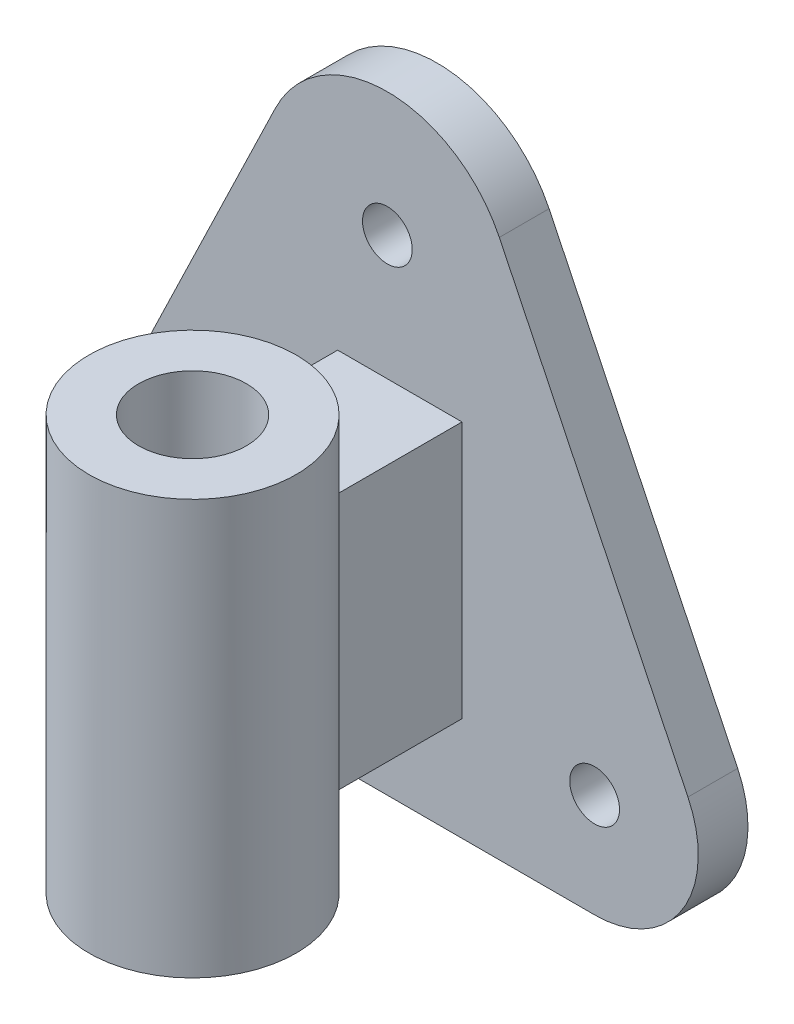
from build123d import *

# Parameters (mm, degrees)
IZIM2_R                     = 6
Y_KSEKLIK_EKSTR_ZYON2_DEPTH = 12
IZIM4_R                     = 25
IZIM4_R_2                   = 13
Y_KSEKLIK_EKSTR_ZYON3_DEPTH = 62
IZIM4_6_R                   = 25
IZIM4_6_R_2                 = 13
Y_KSEKLIK_EKSTR_ZYON4_DEPTH = 19
IZIM5_R                     = 25
IZIM5_R_2                   = 13
Y_KSEKLIK_EKSTR_ZYON5_DEPTH = 19


with BuildPart() as part:
    # Çizim2 → Yükseklik-Ekstrüzyon2 (new body)
    with BuildSketch(Plane.XY):
        with BuildLine():
            Line((17.332096605, 35.875327714), (62.829976007, 130.050393256))
            ThreePointArc((62.829976007, 130.050393256), (89.842699599, 147), (116.85542319, 130.050393256))
            Line((116.85542319, 130.050393256), (162.353302592, 35.875327714))
            ThreePointArc((162.353302592, 35.875327714), (161.019139253, 11.712471879), (139.842699599, 0))
            Line((139.842699599, 0), (39.842699599, 0))
            ThreePointArc((39.842699599, 0), (18.666259945, 11.712471879), (17.332096605, 35.875327714))
        make_face()
        with Locations((89.842699599, 117)):
            Circle(IZIM2_R, mode=Mode.SUBTRACT)
        with Locations((39.842699599, 25)):
            Circle(IZIM2_R, mode=Mode.SUBTRACT)
        with Locations((139.842699599, 25)):
            Circle(IZIM2_R, mode=Mode.SUBTRACT)
    extrude(amount=Y_KSEKLIK_EKSTR_ZYON2_DEPTH)

    # Çizim4 → Yükseklik-Ekstrüzyon3 (add)
    with BuildSketch(Plane(origin=(0, 25, 0), x_dir=(-1, 0, 0), z_dir=(0, -1, 0))):
        with BuildLine():
            ThreePointArc((-107.851357607, -42), (-92.851357607, -37), (-77.851357607, -42))
            Line((-77.851357607, -42), (-77.851357607, -12))
            Line((-77.851357607, -12), (-107.851357607, -12))
            Line((-107.851357607, -12), (-107.851357607, -42))
        make_face()
        with Locations((-92.851357607, -62)):
            Circle(IZIM4_R)
        with Locations(Location((-92.851357607, -62, 0), (0, 0, 90))):
            Circle(IZIM4_R_2, mode=Mode.SUBTRACT)
    extrude(amount=-Y_KSEKLIK_EKSTR_ZYON3_DEPTH)

    # Çizim4<6> → Yükseklik-Ekstrüzyon4 (add)
    with BuildSketch(Plane(origin=(0, 25, 0), x_dir=(-1, 0, 0), z_dir=(0, -1, 0))):
        with Locations(Location((-92.851357607, -62, 0), (0, 0, 90))):
            Circle(IZIM4_6_R)
        with Locations(Location((-92.851357607, -62, 0), (0, 0, 90))):
            Circle(IZIM4_6_R_2, mode=Mode.SUBTRACT)
    extrude(amount=Y_KSEKLIK_EKSTR_ZYON4_DEPTH)

    # Çizim5 → Yükseklik-Ekstrüzyon5 (add)
    with BuildSketch(Plane(origin=(0, 87, 0), x_dir=(1, 0, 0), z_dir=(0, 1, 0))):
        with Locations(Location((92.851357607, -62, 0), (0, 0, 90))):
            Circle(IZIM5_R)
        with Locations(Location((92.851357607, -62, 0), (0, 0, 90))):
            Circle(IZIM5_R_2, mode=Mode.SUBTRACT)
    extrude(amount=Y_KSEKLIK_EKSTR_ZYON5_DEPTH)


solid = part.part
